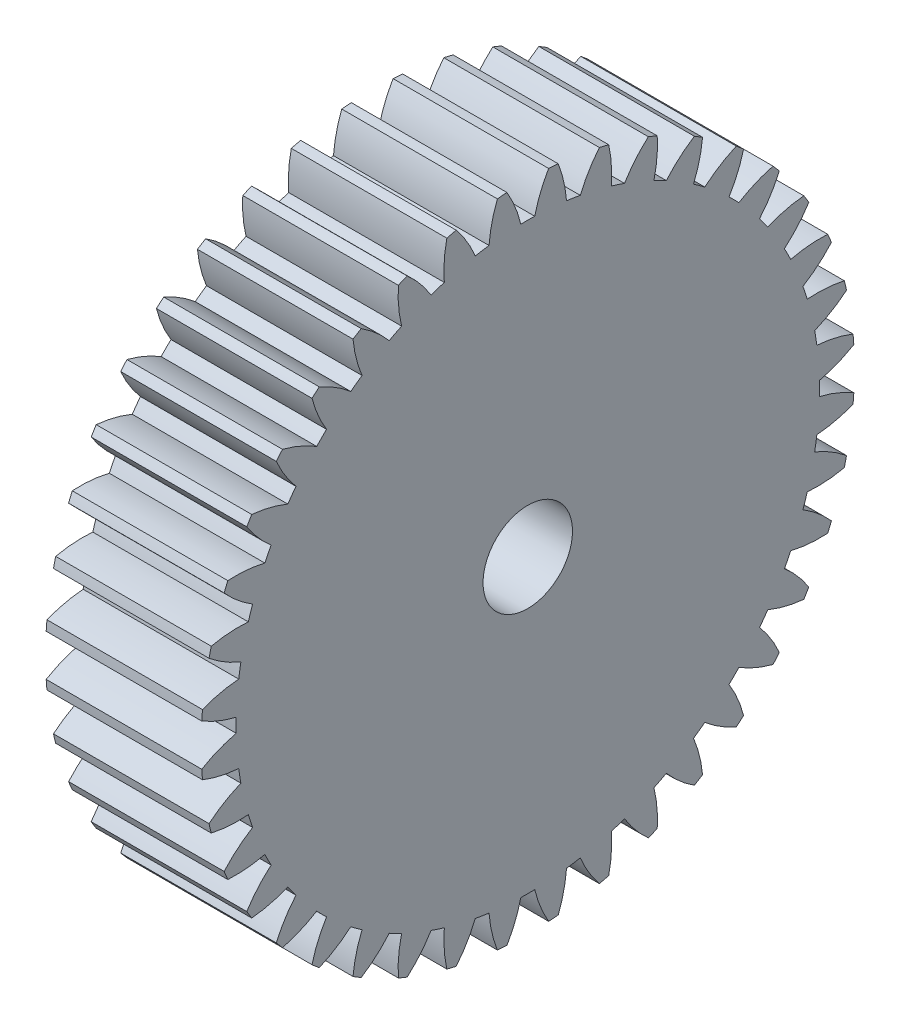
from build123d import *

# Parameters (mm, degrees)
SKETCH1_R           = 0.4
BOSS_EXTRUDE1_DEPTH = 4
SKETCH2_R           = 1.15
CUT_EXTRUDE1_DEPTH  = 5


with BuildPart() as part:
    # Sketch1 → Boss-Extrude1 (new body)
    with BuildSketch(Plane(origin=(-1.595003587, 0, 0), x_dir=(0, 0, -1), z_dir=(1, 0, 0))):
        with BuildLine():
            ThreePointArc((-16.421043875, 7.469942673), (-15.991410659, 7.258334451), (-15.535008147, 7.113215577))
            ThreePointArc((-15.535008147, 7.113215577), (-15.537144789, 6.93421615), (-15.535008147, 6.755216723))
            ThreePointArc((-15.535008147, 6.755216723), (-15.991410659, 6.610097848), (-16.421043875, 6.398489626))
            ThreePointArc((-16.421043875, 6.398489626), (-16.412250392, 6.275159746), (-16.401642569, 6.151972656))
            ThreePointArc((-16.401642569, 6.151972656), (-15.944196031, 6.010179126), (-15.470710998, 5.938243988))
            ThreePointArc((-15.470710998, 5.938243988), (-15.444819655, 5.761114096), (-15.414707639, 5.584652694))
            ThreePointArc((-15.414707639, 5.584652694), (-15.842789485, 5.369923391), (-16.234030385, 5.093710975))
            ThreePointArc((-16.234030385, 5.093710975), (-16.20605212, 4.973275093), (-16.176304191, 4.853264071))
            ThreePointArc((-16.176304191, 4.853264071), (-15.702308183, 4.784776658), (-15.223399402, 4.787796539))
            ThreePointArc((-15.223399402, 4.787796539), (-15.170117605, 4.616897709), (-15.112771672, 4.447319396))
            ThreePointArc((-15.112771672, 4.447319396), (-15.501992057, 4.168267012), (-15.845206991, 3.834251669))
            ThreePointArc((-15.845206991, 3.834251669), (-15.798732862, 3.719675318), (-15.750577319, 3.605795432))
            ThreePointArc((-15.750577319, 3.605795432), (-15.271703197, 3.612300524), (-14.799162991, 3.690201065))
            ThreePointArc((-14.799162991, 3.690201065), (-14.719802714, 3.529741392), (-14.636634912, 3.37122175))
            ThreePointArc((-14.636634912, 3.37122175), (-14.977409938, 3.034717482), (-15.264147815, 2.651123777))
            ThreePointArc((-15.264147815, 2.651123777), (-15.20032217, 2.545228206), (-15.134944762, 2.440283557))
            ThreePointArc((-15.134944762, 2.440283557), (-14.662983996, 2.521620978), (-14.208447873, 2.672484008))
            ThreePointArc((-14.208447873, 2.672484008), (-14.10496323, 2.526414543), (-13.998021427, 2.382856851))
            ThreePointArc((-13.998021427, 2.382856851), (-14.281960081, 1.99718655), (-14.505160462, 1.573459834))
            ThreePointArc((-14.505160462, 1.573459834), (-14.4255549, 1.478852544), (-14.344565436, 1.385427217))
            ThreePointArc((-14.344565436, 1.385427217), (-13.891139267, 1.53959417), (-13.465799416, 1.75970494))
            ThreePointArc((-13.465799416, 1.75970494), (-13.340738541, 1.631622397), (-13.212655998, 1.506561523))
            ThreePointArc((-13.212655998, 1.506561523), (-13.432766769, 1.081221672), (-13.586933722, 0.627795502))
            ThreePointArc((-13.586933722, 0.627795502), (-13.493508395, 0.546806039), (-13.398901105, 0.467200476))
            ThreePointArc((-13.398901105, 0.467200476), (-12.975174389, 0.690400858), (-12.589504088, 0.974339512))
            ThreePointArc((-12.589504088, 0.974339512), (-12.445946396, 0.867397709), (-12.299876931, 0.763913065))
            ThreePointArc((-12.299876931, 0.763913065), (-12.45073996, 0.309376943), (-12.532077382, -0.162583823))
            ThreePointArc((-12.532077382, -0.162583823), (-12.427132733, -0.227961231), (-12.321237162, -0.291786876))
            ThreePointArc((-12.321237162, -0.291786876), (-11.937643457, -0.005048999), (-11.601139189, 0.335726026))
            ThreePointArc((-11.601139189, 0.335726026), (-11.442619547, 0.252558225), (-11.282159874, 0.173197948))
            ThreePointArc((-11.282159874, 0.173197948), (-11.360060414, -0.299342258), (-11.366565507, -0.77821638))
            ThreePointArc((-11.366565507, -0.77821638), (-11.252685621, -0.826371923), (-11.13810927, -0.872846052))
            ThreePointArc((-11.13810927, -0.872846052), (-10.804093926, -0.529631118), (-10.525041542, -0.140410734))
            ThreePointArc((-10.525041542, -0.140410734), (-10.35546323, -0.197756666), (-10.1845644, -0.251038463))
            ThreePointArc((-10.1845644, -0.251038463), (-10.187584281, -0.729947245), (-10.119096868, -1.203943252))
            ThreePointArc((-10.119096868, -1.203943252), (-9.999085845, -1.233691182), (-9.878649964, -1.261669446))
            ThreePointArc((-9.878649964, -1.261669446), (-9.602437548, -0.870428546), (-9.387708245, -0.4423467))
            ThreePointArc((-9.387708245, -0.4423467), (-9.211246842, -0.472458717), (-9.034116951, -0.498350059))
            ThreePointArc((-9.034116951, -0.498350059), (-8.962181813, -0.971835092), (-8.820388282, -1.42928163))
            ThreePointArc((-8.820388282, -1.42928163), (-8.697201193, -1.439889454), (-8.573871312, -1.448682937))
            ThreePointArc((-8.573871312, -1.448682937), (-8.362263091, -1.01904972), (-8.217144216, -0.562647208))
            ThreePointArc((-8.217144216, -0.562647208), (-8.038144789, -0.56478385), (-7.859145362, -0.562647208))
            ThreePointArc((-7.859145362, -0.562647208), (-7.714026487, -1.01904972), (-7.502418266, -1.448682937))
            ThreePointArc((-7.502418266, -1.448682937), (-7.379088385, -1.439889454), (-7.255901296, -1.42928163))
            ThreePointArc((-7.255901296, -1.42928163), (-7.114107765, -0.971835092), (-7.042172627, -0.498350059))
            ThreePointArc((-7.042172627, -0.498350059), (-6.865042736, -0.472458717), (-6.688581333, -0.4423467))
            ThreePointArc((-6.688581333, -0.4423467), (-6.47385203, -0.870428546), (-6.197639614, -1.261669446))
            ThreePointArc((-6.197639614, -1.261669446), (-6.077203733, -1.233691182), (-5.95719271, -1.203943252))
            ThreePointArc((-5.95719271, -1.203943252), (-5.888705297, -0.729947245), (-5.891725178, -0.251038463))
            ThreePointArc((-5.891725178, -0.251038463), (-5.720826348, -0.197756666), (-5.551248036, -0.140410734))
            ThreePointArc((-5.551248036, -0.140410734), (-5.272195652, -0.529631118), (-4.938180308, -0.872846052))
            ThreePointArc((-4.938180308, -0.872846052), (-4.823603957, -0.826371923), (-4.709724071, -0.77821638))
            ThreePointArc((-4.709724071, -0.77821638), (-4.716229164, -0.299342258), (-4.794129704, 0.173197948))
            ThreePointArc((-4.794129704, 0.173197948), (-4.633670031, 0.252558225), (-4.47515039, 0.335726026))
            ThreePointArc((-4.47515039, 0.335726026), (-4.138646121, -0.005048999), (-3.755052416, -0.291786876))
            ThreePointArc((-3.755052416, -0.291786876), (-3.649156845, -0.227961231), (-3.544212196, -0.162583823))
            ThreePointArc((-3.544212196, -0.162583823), (-3.625549618, 0.309376943), (-3.776412647, 0.763913065))
            ThreePointArc((-3.776412647, 0.763913065), (-3.630343182, 0.867397709), (-3.486785491, 0.974339512))
            ThreePointArc((-3.486785491, 0.974339512), (-3.101115189, 0.690400858), (-2.677388473, 0.467200476))
            ThreePointArc((-2.677388473, 0.467200476), (-2.582781183, 0.546806039), (-2.489355857, 0.627795502))
            ThreePointArc((-2.489355857, 0.627795502), (-2.643522809, 1.081221672), (-2.86363358, 1.506561523))
            ThreePointArc((-2.86363358, 1.506561523), (-2.735551037, 1.631622397), (-2.610490163, 1.75970494))
            ThreePointArc((-2.610490163, 1.75970494), (-2.185150311, 1.53959417), (-1.731724142, 1.385427217))
            ThreePointArc((-1.731724142, 1.385427217), (-1.650734678, 1.478852544), (-1.571129116, 1.573459834))
            ThreePointArc((-1.571129116, 1.573459834), (-1.794329498, 1.99718655), (-2.078268151, 2.382856851))
            ThreePointArc((-2.078268151, 2.382856851), (-1.971326348, 2.526414543), (-1.867841705, 2.672484008))
            ThreePointArc((-1.867841705, 2.672484008), (-1.413305582, 2.521620978), (-0.941344816, 2.440283557))
            ThreePointArc((-0.941344816, 2.440283557), (-0.875967408, 2.545228206), (-0.812141763, 2.651123777))
            ThreePointArc((-0.812141763, 2.651123777), (-1.09887964, 3.034717482), (-1.439654666, 3.37122175))
            ThreePointArc((-1.439654666, 3.37122175), (-1.356486864, 3.529741392), (-1.277126587, 3.690201065))
            ThreePointArc((-1.277126587, 3.690201065), (-0.804586381, 3.612300524), (-0.325712259, 3.605795432))
            ThreePointArc((-0.325712259, 3.605795432), (-0.277556716, 3.719675318), (-0.231082588, 3.834251669))
            ThreePointArc((-0.231082588, 3.834251669), (-0.574297521, 4.168267012), (-0.963517906, 4.447319396))
            ThreePointArc((-0.963517906, 4.447319396), (-0.906171973, 4.616897709), (-0.852890176, 4.787796539))
            ThreePointArc((-0.852890176, 4.787796539), (-0.373981395, 4.784776658), (0.100014613, 4.853264071))
            ThreePointArc((0.100014613, 4.853264071), (0.129762542, 4.973275093), (0.157740807, 5.093710975))
            ThreePointArc((0.157740807, 5.093710975), (-0.233500093, 5.369923391), (-0.661581939, 5.584652694))
            ThreePointArc((-0.661581939, 5.584652694), (-0.631469923, 5.761114096), (-0.60557858, 5.938243988))
            ThreePointArc((-0.60557858, 5.938243988), (-0.132093547, 6.010179126), (0.325352991, 6.151972656))
            ThreePointArc((0.325352991, 6.151972656), (0.335960814, 6.275159746), (0.344754297, 6.398489626))
            ThreePointArc((0.344754297, 6.398489626), (-0.08487892, 6.610097848), (-0.541281431, 6.755216723))
            ThreePointArc((-0.541281431, 6.755216723), (-0.539144789, 6.93421615), (-0.541281431, 7.113215577))
            ThreePointArc((-0.541281431, 7.113215577), (-0.08487892, 7.258334451), (0.344754297, 7.469942673))
            ThreePointArc((0.344754297, 7.469942673), (0.335960814, 7.593272554), (0.325352991, 7.716459643))
            ThreePointArc((0.325352991, 7.716459643), (-0.132093547, 7.858253174), (-0.60557858, 7.930188312))
            ThreePointArc((-0.60557858, 7.930188312), (-0.631469923, 8.107318203), (-0.661581939, 8.283779605))
            ThreePointArc((-0.661581939, 8.283779605), (-0.233500093, 8.498508909), (0.157740807, 8.774721324))
            ThreePointArc((0.157740807, 8.774721324), (0.129762542, 8.895157206), (0.100014613, 9.015168229))
            ThreePointArc((0.100014613, 9.015168229), (-0.373981395, 9.083655641), (-0.852890176, 9.08063576))
            ThreePointArc((-0.852890176, 9.08063576), (-0.906171973, 9.25153459), (-0.963517906, 9.421112903))
            ThreePointArc((-0.963517906, 9.421112903), (-0.574297521, 9.700165287), (-0.231082588, 10.03418063))
            ThreePointArc((-0.231082588, 10.03418063), (-0.277556716, 10.148756981), (-0.325712259, 10.262636868))
            ThreePointArc((-0.325712259, 10.262636868), (-0.804586381, 10.256131775), (-1.277126587, 10.178231235))
            ThreePointArc((-1.277126587, 10.178231235), (-1.356486864, 10.338690907), (-1.439654666, 10.497210549))
            ThreePointArc((-1.439654666, 10.497210549), (-1.09887964, 10.833714818), (-0.812141763, 11.217308522))
            ThreePointArc((-0.812141763, 11.217308522), (-0.875967408, 11.323204093), (-0.941344816, 11.428148742))
            ThreePointArc((-0.941344816, 11.428148742), (-1.413305582, 11.346811321), (-1.867841705, 11.195948291))
            ThreePointArc((-1.867841705, 11.195948291), (-1.971326348, 11.342017757), (-2.078268151, 11.485575448))
            ThreePointArc((-2.078268151, 11.485575448), (-1.794329498, 11.871245749), (-1.571129116, 12.294972466))
            ThreePointArc((-1.571129116, 12.294972466), (-1.650734678, 12.389579756), (-1.731724142, 12.483005082))
            ThreePointArc((-1.731724142, 12.483005082), (-2.185150311, 12.32883813), (-2.610490163, 12.108727359))
            ThreePointArc((-2.610490163, 12.108727359), (-2.735551037, 12.236809902), (-2.86363358, 12.361870776))
            ThreePointArc((-2.86363358, 12.361870776), (-2.643522809, 12.787210628), (-2.489355857, 13.240636797))
            ThreePointArc((-2.489355857, 13.240636797), (-2.582781183, 13.321626261), (-2.677388473, 13.401231823))
            ThreePointArc((-2.677388473, 13.401231823), (-3.101115189, 13.178031441), (-3.486785491, 12.894092787))
            ThreePointArc((-3.486785491, 12.894092787), (-3.630343182, 13.00103459), (-3.776412647, 13.104519234))
            ThreePointArc((-3.776412647, 13.104519234), (-3.625549618, 13.559055357), (-3.544212196, 14.031016122))
            ThreePointArc((-3.544212196, 14.031016122), (-3.649156845, 14.09639353), (-3.755052416, 14.160219175))
            ThreePointArc((-3.755052416, 14.160219175), (-4.138646121, 13.873481298), (-4.47515039, 13.532706273))
            ThreePointArc((-4.47515039, 13.532706273), (-4.633670031, 13.615874075), (-4.794129704, 13.695234352))
            ThreePointArc((-4.794129704, 13.695234352), (-4.716229164, 14.167774558), (-4.709724071, 14.646648679))
            ThreePointArc((-4.709724071, 14.646648679), (-4.823603957, 14.694804223), (-4.938180308, 14.741278351))
            ThreePointArc((-4.938180308, 14.741278351), (-5.272195652, 14.398063417), (-5.551248036, 14.008843033))
            ThreePointArc((-5.551248036, 14.008843033), (-5.720826348, 14.066188965), (-5.891725178, 14.119470763))
            ThreePointArc((-5.891725178, 14.119470763), (-5.888705297, 14.598379544), (-5.95719271, 15.072375551))
            ThreePointArc((-5.95719271, 15.072375551), (-6.077203733, 15.102123481), (-6.197639614, 15.130101746))
            ThreePointArc((-6.197639614, 15.130101746), (-6.47385203, 14.738860845), (-6.688581333, 14.310779))
            ThreePointArc((-6.688581333, 14.310779), (-6.865042736, 14.340891016), (-7.042172627, 14.366782359))
            ThreePointArc((-7.042172627, 14.366782359), (-7.114107765, 14.840267392), (-7.255901296, 15.29771393))
            ThreePointArc((-7.255901296, 15.29771393), (-7.379088385, 15.308321753), (-7.502418266, 15.317115236))
            ThreePointArc((-7.502418266, 15.317115236), (-7.714026487, 14.887482019), (-7.859145362, 14.431079507))
            ThreePointArc((-7.859145362, 14.431079507), (-8.038144789, 14.43321615), (-8.217144216, 14.431079507))
            ThreePointArc((-8.217144216, 14.431079507), (-8.362263091, 14.887482019), (-8.573871312, 15.317115236))
            ThreePointArc((-8.573871312, 15.317115236), (-8.697201193, 15.308321753), (-8.820388282, 15.29771393))
            ThreePointArc((-8.820388282, 15.29771393), (-8.962181813, 14.840267392), (-9.034116951, 14.366782359))
            ThreePointArc((-9.034116951, 14.366782359), (-9.211246842, 14.340891016), (-9.387708245, 14.310779))
            ThreePointArc((-9.387708245, 14.310779), (-9.602437548, 14.738860845), (-9.878649964, 15.130101746))
            ThreePointArc((-9.878649964, 15.130101746), (-9.999085845, 15.102123481), (-10.119096868, 15.072375551))
            ThreePointArc((-10.119096868, 15.072375551), (-10.187584281, 14.598379544), (-10.1845644, 14.119470763))
            ThreePointArc((-10.1845644, 14.119470763), (-10.35546323, 14.066188965), (-10.525041542, 14.008843033))
            ThreePointArc((-10.525041542, 14.008843033), (-10.804093926, 14.398063417), (-11.13810927, 14.741278351))
            ThreePointArc((-11.13810927, 14.741278351), (-11.252685621, 14.694804223), (-11.366565507, 14.646648679))
            ThreePointArc((-11.366565507, 14.646648679), (-11.360060414, 14.167774558), (-11.282159874, 13.695234352))
            ThreePointArc((-11.282159874, 13.695234352), (-11.442619547, 13.615874075), (-11.601139189, 13.532706273))
            ThreePointArc((-11.601139189, 13.532706273), (-11.937643457, 13.873481298), (-12.321237162, 14.160219175))
            ThreePointArc((-12.321237162, 14.160219175), (-12.427132733, 14.09639353), (-12.532077382, 14.031016122))
            ThreePointArc((-12.532077382, 14.031016122), (-12.45073996, 13.559055357), (-12.299876931, 13.104519234))
            ThreePointArc((-12.299876931, 13.104519234), (-12.445946396, 13.00103459), (-12.589504088, 12.894092787))
            ThreePointArc((-12.589504088, 12.894092787), (-12.975174389, 13.178031441), (-13.398901105, 13.401231823))
            ThreePointArc((-13.398901105, 13.401231823), (-13.493508395, 13.321626261), (-13.586933722, 13.240636797))
            ThreePointArc((-13.586933722, 13.240636797), (-13.432766769, 12.787210628), (-13.212655998, 12.361870776))
            ThreePointArc((-13.212655998, 12.361870776), (-13.340738541, 12.236809902), (-13.465799416, 12.108727359))
            ThreePointArc((-13.465799416, 12.108727359), (-13.891139267, 12.32883813), (-14.344565436, 12.483005082))
            ThreePointArc((-14.344565436, 12.483005082), (-14.4255549, 12.389579756), (-14.505160462, 12.294972466))
            ThreePointArc((-14.505160462, 12.294972466), (-14.281960081, 11.871245749), (-13.998021427, 11.485575448))
            ThreePointArc((-13.998021427, 11.485575448), (-14.10496323, 11.342017757), (-14.208447873, 11.195948291))
            ThreePointArc((-14.208447873, 11.195948291), (-14.662983996, 11.346811321), (-15.134944762, 11.428148742))
            ThreePointArc((-15.134944762, 11.428148742), (-15.20032217, 11.323204093), (-15.264147815, 11.217308522))
            ThreePointArc((-15.264147815, 11.217308522), (-14.977409938, 10.833714818), (-14.636634912, 10.497210549))
            ThreePointArc((-14.636634912, 10.497210549), (-14.719802714, 10.338690907), (-14.799162991, 10.178231235))
            ThreePointArc((-14.799162991, 10.178231235), (-15.271703197, 10.256131775), (-15.750577319, 10.262636868))
            ThreePointArc((-15.750577319, 10.262636868), (-15.798732862, 10.148756981), (-15.845206991, 10.03418063))
            ThreePointArc((-15.845206991, 10.03418063), (-15.501992057, 9.700165287), (-15.112771672, 9.421112903))
            ThreePointArc((-15.112771672, 9.421112903), (-15.170117605, 9.25153459), (-15.223399402, 9.08063576))
            ThreePointArc((-15.223399402, 9.08063576), (-15.702308183, 9.083655641), (-16.176304191, 9.015168229))
            ThreePointArc((-16.176304191, 9.015168229), (-16.20605212, 8.895157206), (-16.234030385, 8.774721324))
            ThreePointArc((-16.234030385, 8.774721324), (-15.842789485, 8.498508909), (-15.414707639, 8.283779605))
            ThreePointArc((-15.414707639, 8.283779605), (-15.444819655, 8.107318203), (-15.470710998, 7.930188312))
            ThreePointArc((-15.470710998, 7.930188312), (-15.944196031, 7.858253174), (-16.401642569, 7.716459643))
            ThreePointArc((-16.401642569, 7.716459643), (-16.412250392, 7.593272554), (-16.421043875, 7.469942673))
        make_face()
        with Locations((-8.038144789, 6.93421615)):
            Circle(SKETCH1_R, mode=Mode.SUBTRACT)
    extrude(amount=-BOSS_EXTRUDE1_DEPTH)

    # Sketch2 → Cut-Extrude1 (cut, through all)
    with BuildSketch(Plane(origin=(-1.595003587, 0, 0), x_dir=(0, 0, -1), z_dir=(1, 0, 0))):
        with Locations((-8.038144789, 6.93421615)):
            Circle(SKETCH2_R)
    extrude(amount=-CUT_EXTRUDE1_DEPTH, mode=Mode.SUBTRACT)


solid = part.part
